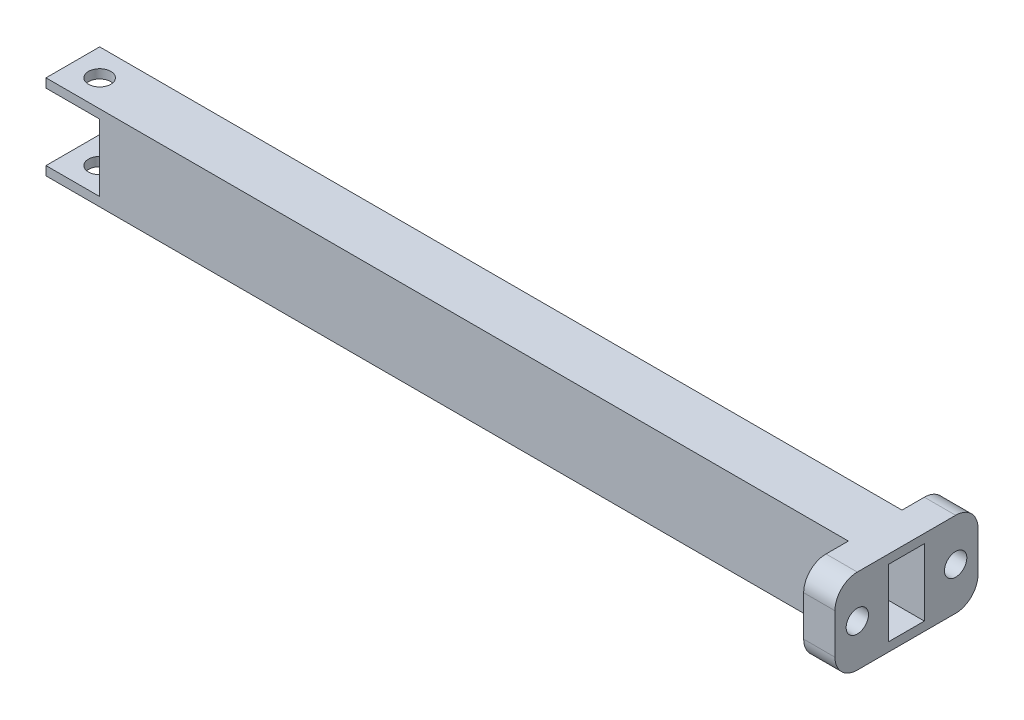
from build123d import *

# Parameters (mm, degrees)
CROQUIS1_W              = 12
CROQUIS1_H              = 19
CROQUIS1_W_2            = 8
CROQUIS1_H_2            = 15
SALIENTE_EXTRUIR1_DEPTH = 186.5
CROQUIS2_W              = 12
CROQUIS2_H              = 15
CORTAR_EXTRUIR1_DEPTH   = 12
CROQUIS3_R              = 2.5
CORTAR_EXTRUIR2_DEPTH   = 19
SKETCH1_W               = 186.5
SKETCH1_H               = 19
CUT_EXTRUDE1_DEPTH      = 13
SKETCH2_W               = 7
SKETCH2_H               = 19
BOSS_EXTRUDE1_DEPTH     = 10
SKETCH3_R               = 2.5
CUT_EXTRUDE2_DEPTH      = 10
FILLET1_R               = 5
FILLET2_R               = 5


with BuildPart() as part:
    # Croquis1 → Saliente-Extruir1 (new body, symmetric)
    with BuildSketch(Plane(origin=(0, 0, 0), x_dir=(0, 0, -1), z_dir=(1, 0, 0))):
        Rectangle(CROQUIS1_W, CROQUIS1_H)
        Rectangle(CROQUIS1_W_2, CROQUIS1_H_2, mode=Mode.SUBTRACT)
    extrude(amount=SALIENTE_EXTRUIR1_DEPTH, both=True)

    # Croquis2 → Cortar-Extruir1 (cut)
    with BuildSketch(Plane.XY.offset(6)):
        with Locations((-180.5, 0)):
            Rectangle(CROQUIS2_W, CROQUIS2_H)
        with Locations((180.5, 0)):
            Rectangle(CROQUIS2_W, CROQUIS2_H)
    extrude(amount=-CORTAR_EXTRUIR1_DEPTH, mode=Mode.SUBTRACT)

    # Croquis3 → Cortar-Extruir2 (cut)
    with BuildSketch(Plane(origin=(0, 9.5, 0), x_dir=(1, 0, 0), z_dir=(0, 1, 0))):
        with Locations((-180.5, 0)):
            Circle(CROQUIS3_R)
        with Locations((180.5, 0)):
            Circle(CROQUIS3_R)
    extrude(amount=-CORTAR_EXTRUIR2_DEPTH, mode=Mode.SUBTRACT)

    # Sketch1 → Cut-Extrude1 (cut, through all)
    with BuildSketch(Plane.XY.offset(6)):
        with Locations((93.25, 0)):
            Rectangle(SKETCH1_W, SKETCH1_H)
    extrude(amount=-CUT_EXTRUDE1_DEPTH, mode=Mode.SUBTRACT)

    # Sketch2 → Boss-Extrude1 (add)
    with BuildSketch(Plane.XY.offset(6)):
        with Locations((-3.5, 0)):
            Rectangle(SKETCH2_W, SKETCH2_H)
    boss_extrude1 = extrude(amount=BOSS_EXTRUDE1_DEPTH)

    # Sketch3 → Cut-Extrude2 (cut)
    with BuildSketch(Plane(origin=(0, 0, 0), x_dir=(0, 0, -1), z_dir=(1, 0, 0))):
        with Locations((-11, 0)):
            Circle(SKETCH3_R)
    cut_extrude2 = extrude(amount=-CUT_EXTRUDE2_DEPTH, mode=Mode.SUBTRACT)

    # Fillet1
    fillet1_edges = [part.edges().sort_by_distance(p)[0] for p in [
        (-3.5, 9.5, 16),
        (-3.5, -9.5, 16),
    ]]
    fillet(fillet1_edges, radius=FILLET1_R)

    # Mirror1: Boss-Extrude1, Cut-Extrude2 across plane
    add(boss_extrude1.mirror(Plane.XY))
    add(cut_extrude2.mirror(Plane.XY), mode=Mode.SUBTRACT)

    # Fillet2
    fillet2_edges = [part.edges().sort_by_distance(p)[0] for p in [
        (-3.5, -9.5, -16),
        (-3.5, 9.5, -16),
    ]]
    fillet(fillet2_edges, radius=FILLET2_R)


solid = part.part
